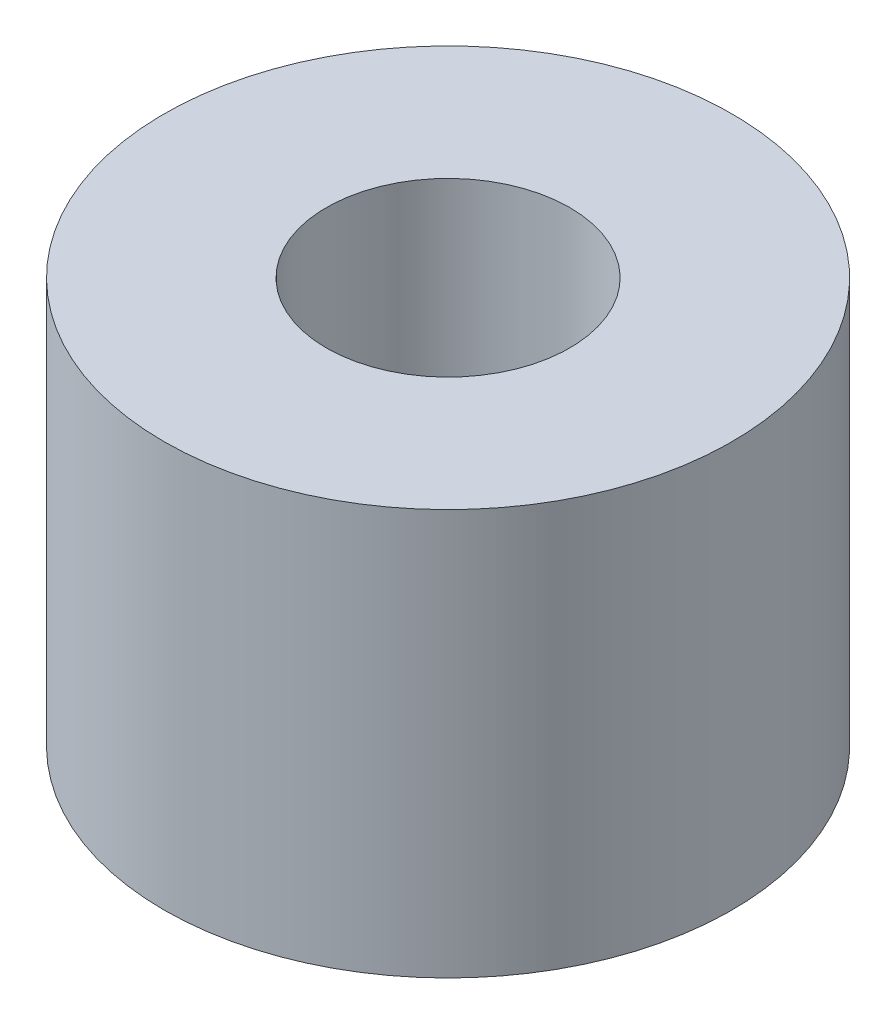
from build123d import *

# Parameters (mm, degrees)
SKETCH2_R           = 3.5
SKETCH2_R_2         = 1.5
BOSS_EXTRUDE1_DEPTH = 5


with BuildPart() as part:
    # Sketch2 → Boss-Extrude1 (new body)
    with BuildSketch(Plane(origin=(0, 0, 0), x_dir=(1, 0, 0), z_dir=(0, 1, 0))):
        Circle(SKETCH2_R)
        Circle(SKETCH2_R_2, mode=Mode.SUBTRACT)
    extrude(amount=BOSS_EXTRUDE1_DEPTH)


solid = part.part
